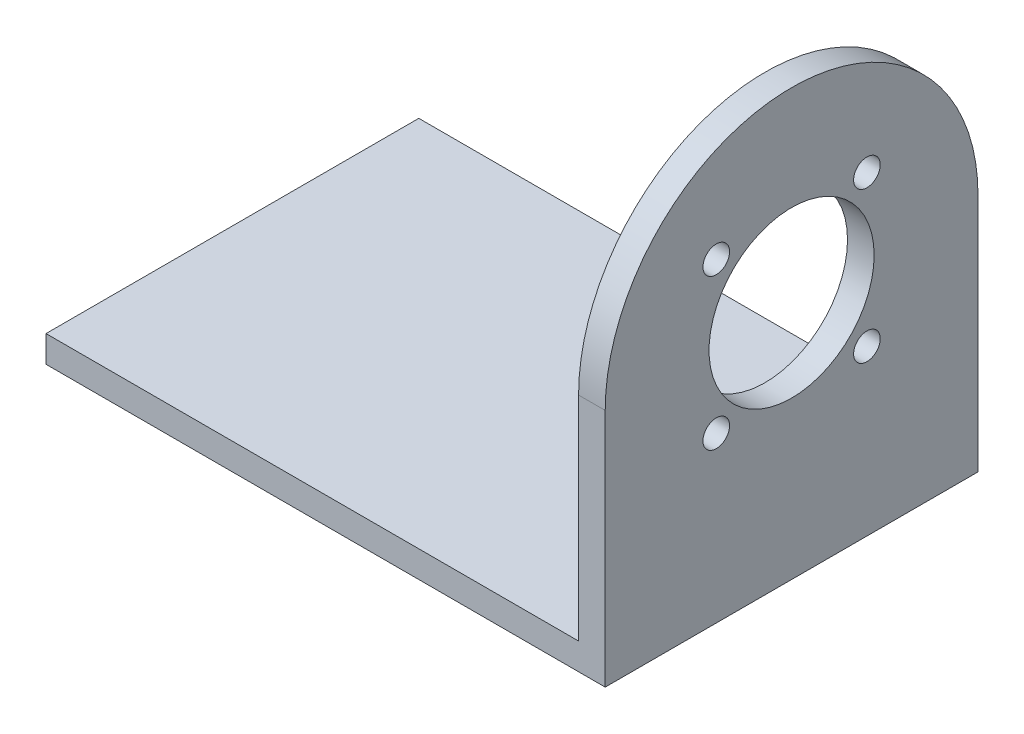
from build123d import *

# Parameters (mm, degrees)
SKETCH1_W           = 105
SKETCH1_H           = 70
BOSS_EXTRUDE1_DEPTH = 5
SKETCH2_W           = 5
SKETCH2_H           = 70
BOSS_EXTRUDE2_DEPTH = 70
CUT_EXTRUDE1_DEPTH  = 20
SKETCH4_R           = 25.5
CUT_EXTRUDE2_DEPTH  = 10
BOSS_EXTRUDE3_DEPTH = 5
SKETCH6_R           = 25.5
SKETCH6_R_2         = 15.5
BOSS_EXTRUDE4_DEPTH = 5
SKETCH7_R           = 2.5
CUT_EXTRUDE3_DEPTH  = 5


with BuildPart() as part:
    # Sketch1 → Boss-Extrude1 (new body)
    with BuildSketch(Plane(origin=(0, 0, 0), x_dir=(1, 0, 0), z_dir=(0, 1, 0))):
        Rectangle(SKETCH1_W, SKETCH1_H)
    extrude(amount=BOSS_EXTRUDE1_DEPTH)

    # Sketch2 → Boss-Extrude2 (add)
    with BuildSketch(Plane(origin=(0, 5, 0), x_dir=(1, 0, 0), z_dir=(0, 1, 0))):
        with Locations((50, 0)):
            Rectangle(SKETCH2_W, SKETCH2_H)
    extrude(amount=BOSS_EXTRUDE2_DEPTH)

    # Sketch3 → Cut-Extrude1 (cut)
    with BuildSketch(Plane.ZY.offset(-47.5)):
        with BuildLine():
            Line((-18.027756377, 75), (-35, 75))
            Line((-35, 75), (-35, 45))
            ThreePointArc((-35, 45), (-30.462858313, 62.234101758), (-18.027756377, 75))
        make_face()
        with BuildLine():
            Line((35, 75), (18.027756377, 75))
            ThreePointArc((18.027756377, 75), (30.462858313, 62.234101758), (35, 45))
            Line((35, 45), (35, 75))
        make_face()
    extrude(amount=-CUT_EXTRUDE1_DEPTH, mode=Mode.SUBTRACT)

    # Sketch4 → Cut-Extrude2 (cut)
    with BuildSketch(Plane.ZY.offset(-47.5)):
        with Locations((0, 45)):
            Circle(SKETCH4_R)
    extrude(amount=-CUT_EXTRUDE2_DEPTH, mode=Mode.SUBTRACT)

    # Sketch5 → Boss-Extrude3 (add)
    with BuildSketch(Plane(origin=(52.5, 0, 0), x_dir=(0, 0, -1), z_dir=(1, 0, 0))):
        with BuildLine():
            Line((-18.027756377, 75), (18.027756377, 75))
            ThreePointArc((18.027756377, 75), (0, 80), (-18.027756377, 75))
        make_face()
    extrude(amount=-BOSS_EXTRUDE3_DEPTH)

    # Sketch6 → Boss-Extrude4 (add)
    with BuildSketch(Plane(origin=(52.5, 0, 0), x_dir=(0, 0, -1), z_dir=(1, 0, 0))):
        with Locations((0, 45)):
            Circle(SKETCH6_R)
        with Locations((0, 45)):
            Circle(SKETCH6_R_2, mode=Mode.SUBTRACT)
    extrude(amount=-BOSS_EXTRUDE4_DEPTH)

    # Sketch7 → Cut-Extrude3 (cut)
    with BuildSketch(Plane(origin=(52.5, 0, 0), x_dir=(0, 0, -1), z_dir=(1, 0, 0))):
        with Locations((14.142135624, 59.142135624)):
            Circle(SKETCH7_R)
        with Locations((14.142135624, 30.857864376)):
            Circle(SKETCH7_R)
        with Locations((-14.142135624, 30.857864376)):
            Circle(SKETCH7_R)
        with Locations((-14.142135624, 59.142135624)):
            Circle(SKETCH7_R)
    extrude(amount=-CUT_EXTRUDE3_DEPTH, mode=Mode.SUBTRACT)


solid = part.part
